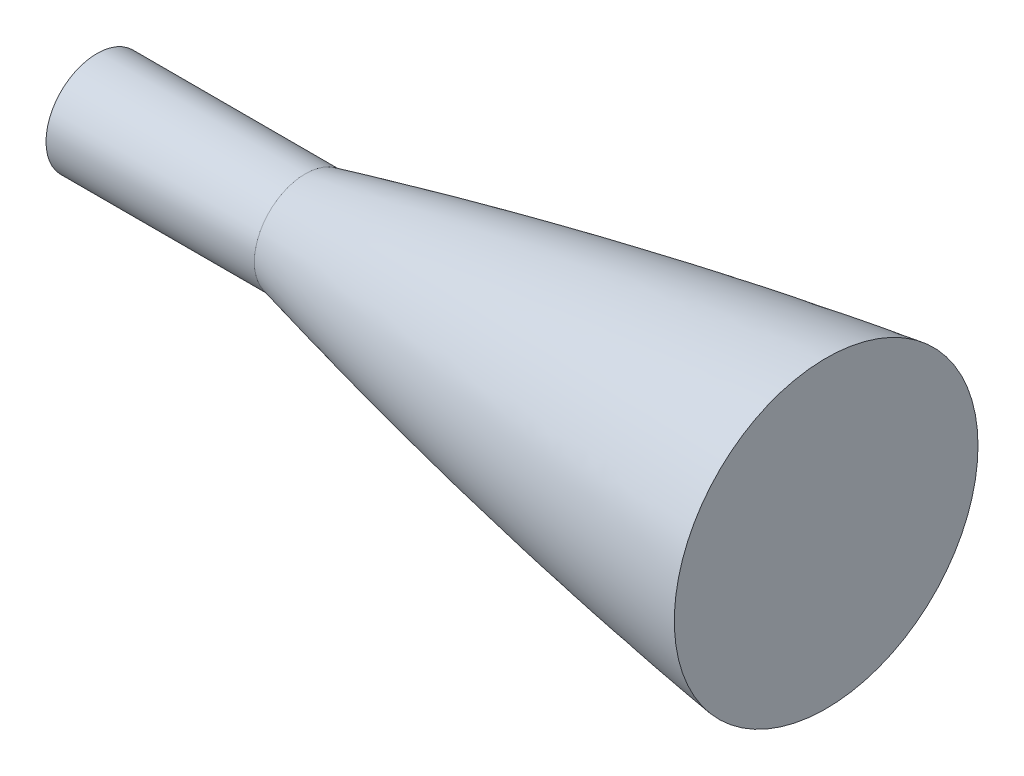
from build123d import *

# Parameters (mm, degrees)
SKETCH2_R           = 49.53
BOSS_EXTRUDE1_DEPTH = 203.2
SKETCH3_R           = 12.411567775
BOSS_EXTRUDE2_DEPTH = 50.8
SKETCH4_R           = 49.53
CUT_EXTRUDE1_DEPTH  = 381
SKETCH5_R           = 49.53
CUT_EXTRUDE2_DEPTH  = 381


with BuildPart() as part:
    # Sketch1 → Revolve2 (revolve)
    with BuildSketch(Plane(origin=(0, 0, 0), x_dir=(1, 0, 0), z_dir=(0, 1, 0))):
        with BuildLine():
            Line((355.600000053, 50.799999973), (355.600000053, 1.269999973))
            Line((355.600000053, 1.269999973), (50.800000047, 1.269999973))
            Line((50.800000047, 1.269999973), (50.800000047, 13.68156774))
            add(Edge.make_bspline(
                [(50.800000047, 13.68156774), (51.224607869, 13.786541703), (52.079748124, 13.99736018), (53.901316113, 14.445024847), (55.90428978, 14.933081433), (57.918204029, 15.420277853), (59.969167456, 15.913068852), (62.005618607, 16.398707152), (64.04585603, 16.881716673), (66.619566178, 17.486536085), (69.727395203, 18.209576077), (73.370678613, 19.04644661), (77.55044141, 19.991710093), (82.779136229, 21.155661521), (97.433989811, 24.348822924), (119.485629173, 28.81699746), (168.00075752, 37.516041455), (219.035004801, 44.081341124), (262.822405655, 47.820230422), (299.206459448, 49.570692635), (308.841173655, 49.947366018), (315.265578413, 50.162354186), (319.548981494, 50.29122703), (323.832782669, 50.405645805), (328.116966628, 50.505609209), (332.401425999, 50.591116104), (336.139078075, 50.653092889), (339.329601827, 50.697064227), (341.973247658, 50.727612371), (344.069774299, 50.748376802), (346.163273231, 50.76568058), (348.272494467, 50.77952366), (350.344714481, 50.789906003), (352.405704949, 50.79682758), (354.282013928, 50.799423175), (355.162608625, 50.799999974), (355.600000053, 50.799999973)],
                knots=[0.08282658, 0.08282658, 0.08282658, 0.08282658, 0.08282658, 0.088510594, 0.094194608, 0.099878623, 0.105562637, 0.111246651, 0.116930666, 0.12261468, 0.128298694, 0.139917182, 0.15153567, 0.163154157, 0.174772645, 0.198009616, 0.314194483, 0.407142375, 0.709223026, 0.755696971, 0.790552431, 0.802170918, 0.813789405, 0.825407891, 0.837026378, 0.848644864, 0.860263351, 0.871881838, 0.877565852, 0.883249866, 0.88893388, 0.894617894, 0.900301908, 0.905985922, 0.911669936, 0.91735395, 0.91735395, 0.91735395, 0.91735395, 0.91735395], degree=4))
        make_face()
    revolve(axis=Axis((355.600000053, 0, -1.269999973), (-1, 0, 0)))

    # Sketch2 → Boss-Extrude1 (add)
    with BuildSketch(Plane(origin=(355.600000053, 0, 0), x_dir=(0, 0, -1), z_dir=(1, 0, 0))):
        with Locations((1.269999973, 0)):
            Circle(SKETCH2_R)
    extrude(amount=BOSS_EXTRUDE1_DEPTH)

    # Sketch3 → Boss-Extrude2 (add)
    with BuildSketch(Plane.ZY.offset(-50.800000063)):
        with Locations((-1.269999973, 0)):
            Circle(SKETCH3_R)
    extrude(amount=BOSS_EXTRUDE2_DEPTH)

    # Sketch4 → Cut-Extrude1 (cut)
    with BuildSketch(Plane(origin=(368.300000053, 0, 0), x_dir=(0, 0, -1), z_dir=(1, 0, 0))):
        with Locations((1.269999973, 0)):
            Circle(SKETCH4_R)
    extrude(amount=CUT_EXTRUDE1_DEPTH, mode=Mode.SUBTRACT)

    # Sketch5 → Cut-Extrude2 (cut)
    with BuildSketch(Plane(origin=(177.800000053, 0, 0), x_dir=(0, 0, -1), z_dir=(1, 0, 0))):
        with Locations((1.269999973, 0)):
            Circle(SKETCH5_R)
    extrude(amount=CUT_EXTRUDE2_DEPTH, mode=Mode.SUBTRACT)


solid = part.part
